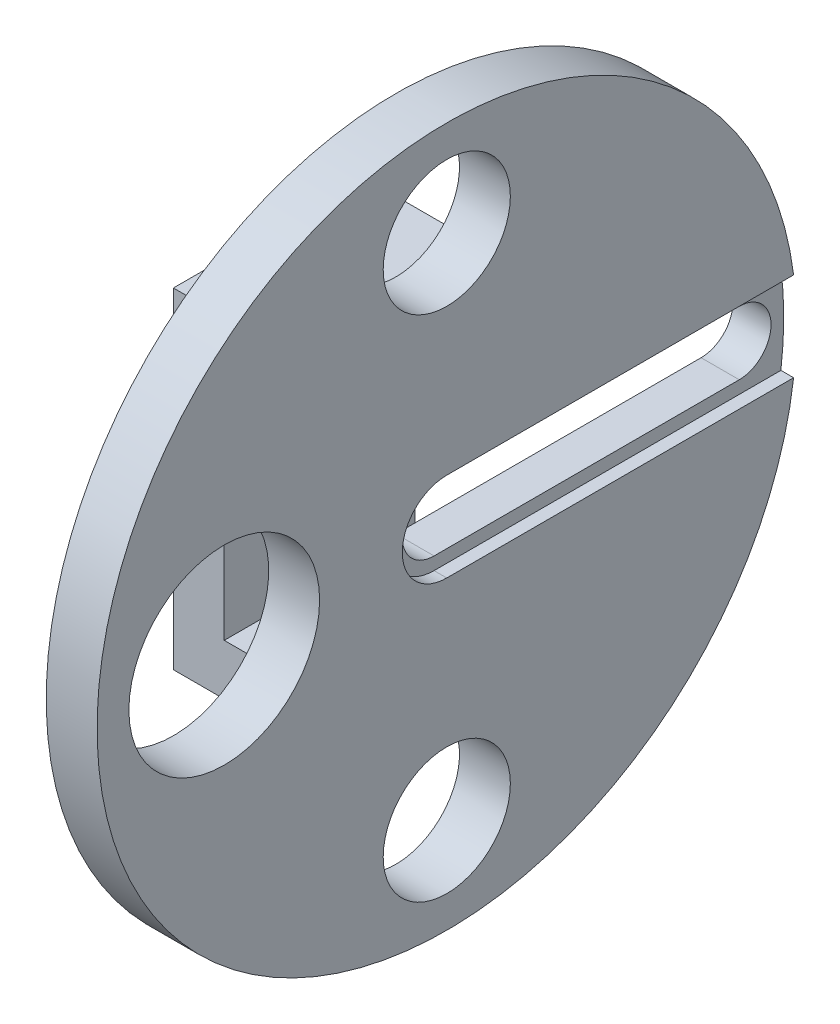
from build123d import *

# Parameters (mm, degrees)
SKETCH_1_R          = 7.5
EXTRUDE_1_DEPTH     = 10
SKETCH_5_W          = 30
SKETCH_5_H          = 52
EXTRUDE_2_DEPTH     = 8
SKETCH_6_W          = 30
SKETCH_6_H          = 8
EXTRUDE_3_DEPTH     = 12
SKETCH_7_R          = 55
EXTRUDE_4_DEPTH     = 8
CUT_EXTRUDE_4_REACH = 40
CUT_EXTRUDE_6_DEPTH = 2
CUT_EXTRUDE_7_REACH = 40
SKETCH_12_R         = 9
SKETCH_13_R         = 10
SKETCH_13_R_2       = 15
CUT_EXTRUDE_8_DEPTH = 10


with BuildPart() as part:
    # 草图1 → 凸台-拉伸1 (new body)
    with BuildSketch(Plane(origin=(0, 0, 0), x_dir=(0, 0, -1), z_dir=(1, 0, 0))):
        Circle(SKETCH_1_R)
    extrude(amount=EXTRUDE_1_DEPTH)

    # 草图5 → 凸台-拉伸2 (add)
    with BuildSketch(Plane(origin=(10, 0, 0), x_dir=(0, 0, -1), z_dir=(1, 0, 0))):
        Rectangle(SKETCH_5_W, SKETCH_5_H)
    extrude(amount=EXTRUDE_2_DEPTH)

    # 草图6 → 凸台-拉伸3 (add)
    with BuildSketch(Plane(origin=(18, 0, 0), x_dir=(0, 0, -1), z_dir=(1, 0, 0))):
        with Locations((0, 22)):
            Rectangle(SKETCH_6_W, SKETCH_6_H)
        with Locations((0, -22)):
            Rectangle(SKETCH_6_W, SKETCH_6_H)
    extrude(amount=EXTRUDE_3_DEPTH)

    # 草图7 → 凸台-拉伸4 (add)
    with BuildSketch(Plane(origin=(30, 0, 0), x_dir=(0, 0, -1), z_dir=(1, 0, 0))):
        Circle(SKETCH_7_R)
    extrude(amount=EXTRUDE_4_DEPTH)

    # 草图8 → 切除-拉伸4 (cut, up to next)
    with BuildSketch(Plane(origin=(38, 0, 0), x_dir=(0, 0, -1), z_dir=(1, 0, 0)), mode=Mode.PRIVATE) as cut_extrude_4_sk1:
        with BuildLine():
            Line((0, 5), (48, 5))
            ThreePointArc((48, 5), (53, 0), (48, -5))
            Line((48, -5), (0, -5))
            ThreePointArc((0, -5), (-5, 0), (0, 5))
        make_face()
    cut_extrude_4_tool1 = extrude(cut_extrude_4_sk1.sketch, amount=-CUT_EXTRUDE_4_REACH, mode=Mode.PRIVATE) & part.part
    add(cut_extrude_4_tool1.solids().sort_by_distance((38, 0, -24))[0], mode=Mode.SUBTRACT)

    # 草图11 → 切除-拉伸6 (cut)
    with BuildSketch(Plane(origin=(38, 0, 0), x_dir=(0, 0, -1), z_dir=(1, 0, 0))):
        with BuildLine():
            Line((0, 7), (54.552726788, 7))
            ThreePointArc((54.552726788, 7), (55, 0), (54.552726788, -7))
            Line((54.552726788, -7), (0, -7))
            ThreePointArc((0, -7), (-7, 0), (0, 7))
        make_face()
    extrude(amount=-CUT_EXTRUDE_6_DEPTH, mode=Mode.SUBTRACT)

    # 草图12 → 切除-拉伸7 (cut, up to next)
    with BuildSketch(Plane.ZY, mode=Mode.PRIVATE) as cut_extrude_7_sk1:
        Circle(SKETCH_12_R)
    cut_extrude_7_tool1 = extrude(cut_extrude_7_sk1.sketch, amount=-CUT_EXTRUDE_7_REACH, mode=Mode.PRIVATE) & part.part
    add(cut_extrude_7_tool1.solids().sort_by_distance((0, 0, 0))[0], mode=Mode.SUBTRACT)

    # 草图13 → 切除-拉伸8 (cut)
    with BuildSketch(Plane.ZY.offset(-30)):
        with Locations((0, 40)):
            Circle(SKETCH_13_R)
        with Locations((35, 0)):
            Circle(SKETCH_13_R_2)
        with Locations((0, -40)):
            Circle(SKETCH_13_R)
    extrude(amount=-CUT_EXTRUDE_8_DEPTH, mode=Mode.SUBTRACT)


solid = part.part
